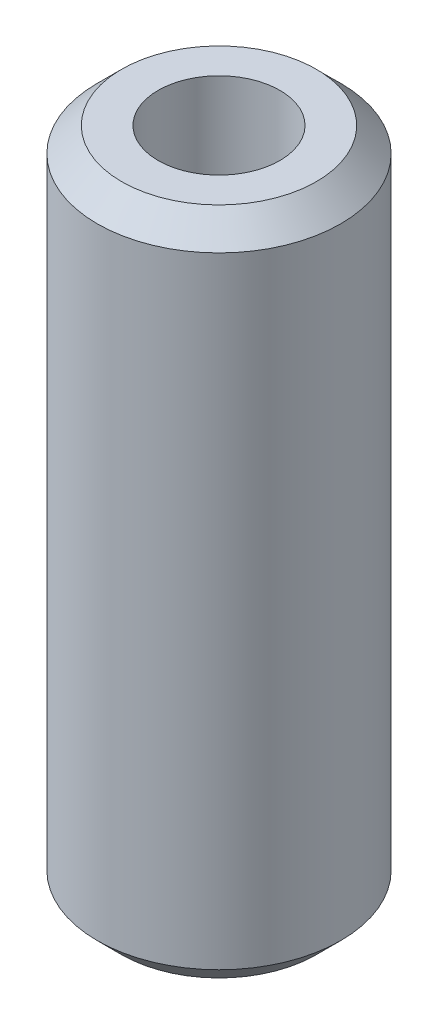
from build123d import *

# Parameters (mm, degrees)
SKETCH1_R           = 12.7
SKETCH1_R_2         = 6.35
BOSS_EXTRUDE1_DEPTH = 34.925
CHAMFER1_SIZE       = 2.54


with BuildPart() as part:
    # Sketch1 → Boss-Extrude1 (new body, symmetric)
    with BuildSketch(Plane(origin=(0, 0, 0), x_dir=(1, 0, 0), z_dir=(0, 1, 0))):
        Circle(SKETCH1_R)
        Circle(SKETCH1_R_2, mode=Mode.SUBTRACT)
    extrude(amount=BOSS_EXTRUDE1_DEPTH, both=True)

    # Chamfer1
    chamfer1_edges = [part.edges().sort_by_distance(p)[0] for p in [
        (-12.7, -34.925, 0),
        (-12.7, 34.925, 0),
    ]]
    chamfer(chamfer1_edges, length=CHAMFER1_SIZE)


solid = part.part
